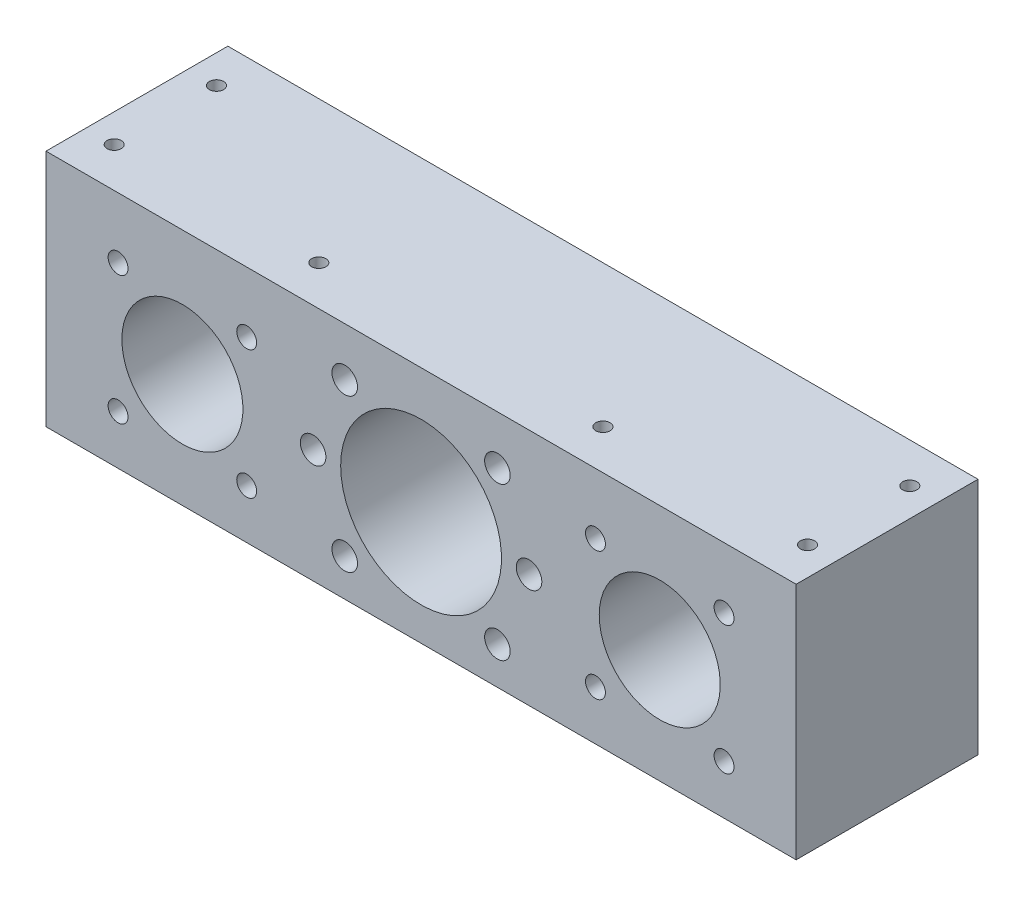
from build123d import *

# Parameters (mm, degrees)
SKETCH_1_W           = 132
SKETCH_1_H           = 42
EXTRUDE_1_DEPTH      = 32
SKETCH_2_R           = 14.15
CUT_EXTRUDE_1_DEPTH  = 32
SKETCH_3_R           = 10.65
CUT_EXTRUDE_2_DEPTH  = 32
SKETCH_7_R           = 2.25
SKETCH_7_R_2         = 1.75
CUT_EXTRUDE_8_DEPTH  = 32
CUT_EXTRUDE_9_DEPTH  = 10
CUT_EXTRUDE_10_DEPTH = 6
SKETCH_10_R          = 1.25
CUT_EXTRUDE_26_DEPTH = 10


with BuildPart() as part:
    # 草图1 → 凸台-拉伸1 (new body)
    with BuildSketch(Plane.XY):
        with Locations((0, 1)):
            Rectangle(SKETCH_1_W, SKETCH_1_H)
    extrude(amount=EXTRUDE_1_DEPTH)

    # 草图2 → 切除-拉伸1 (cut)
    with BuildSketch(Plane(origin=(0, 0, 0), x_dir=(-1, 0, 0), z_dir=(0, 0, -1))):
        Circle(SKETCH_2_R)
    extrude(amount=-CUT_EXTRUDE_1_DEPTH, mode=Mode.SUBTRACT)

    # 草图3 → 切除-拉伸2 (cut)
    with BuildSketch(Plane(origin=(0, 0, 0), x_dir=(-1, 0, 0), z_dir=(0, 0, -1))):
        with Locations((-42, 0)):
            Circle(SKETCH_3_R)
        with Locations((42, 0)):
            Circle(SKETCH_3_R)
    extrude(amount=-CUT_EXTRUDE_2_DEPTH, mode=Mode.SUBTRACT)

    # 草图7 → 切除-拉伸8 (cut)
    with BuildSketch(Plane(origin=(0, 0, 0), x_dir=(-1, 0, 0), z_dir=(0, 0, -1))):
        with Locations((-13.435028843, 13.435028843)):
            Circle(SKETCH_7_R)
        with Locations((13.435028843, 13.435028843)):
            Circle(SKETCH_7_R)
        with Locations((13.435028843, -13.435028843)):
            Circle(SKETCH_7_R)
        with Locations((-13.435028843, -13.435028843)):
            Circle(SKETCH_7_R)
        with Locations((-18.998610576, 0)):
            Circle(SKETCH_7_R)
        with Locations((18.998532389, 0)):
            Circle(SKETCH_7_R)
        with Locations((30.686291501, 11.313708499)):
            Circle(SKETCH_7_R_2)
        with Locations((30.686291501, -11.313708499)):
            Circle(SKETCH_7_R_2)
        with Locations((53.313708499, 11.313708499)):
            Circle(SKETCH_7_R_2)
        with Locations((53.313708499, -11.313708499)):
            Circle(SKETCH_7_R_2)
        with Locations((-53.313708499, 11.313708499)):
            Circle(SKETCH_7_R_2)
        with Locations((-30.686291501, 11.313708499)):
            Circle(SKETCH_7_R_2)
        with Locations((-53.313708499, -11.313708499)):
            Circle(SKETCH_7_R_2)
        with Locations((-30.686291501, -11.313708499)):
            Circle(SKETCH_7_R_2)
    extrude(amount=-CUT_EXTRUDE_8_DEPTH, mode=Mode.SUBTRACT)

    # 草图8 → 切除-拉伸9 (cut)
    with BuildSketch(Plane(origin=(0, 0, 0), x_dir=(-1, 0, 0), z_dir=(0, 0, -1))):
        with BuildLine():
            Line((-13.417246364, 20.2), (13.417246364, 20.2))
            ThreePointArc((13.417246364, 20.2), (24.249341133, 0.178758535), (13.713588152, -20))
            Line((13.713588152, -20), (-13.713588152, -20))
            ThreePointArc((-13.713588152, -20), (-24.249341133, 0.178758535), (-13.417246364, 20.2))
        make_face()
    extrude(amount=-CUT_EXTRUDE_9_DEPTH, mode=Mode.SUBTRACT)

    # 草图9 → 切除-拉伸10 (cut)
    with BuildSketch(Plane(origin=(0, 0, 0), x_dir=(-1, 0, 0), z_dir=(0, 0, -1))):
        with BuildLine():
            Line((28.306936062, 16.25), (55.693063938, 16.25))
            ThreePointArc((55.693063938, 16.25), (57.0260191, 15.0260191), (58.25, 13.693063938))
            Line((58.25, 13.693063938), (58.25, -13.693063938))
            ThreePointArc((58.25, -13.693063938), (57.0260191, -15.0260191), (55.693063938, -16.25))
            Line((55.693063938, -16.25), (28.306936062, -16.25))
            ThreePointArc((28.306936062, -16.25), (26.9739809, -15.0260191), (25.75, -13.693063938))
            Line((25.75, -13.693063938), (25.75, 13.693063938))
            ThreePointArc((25.75, 13.693063938), (26.9739809, 15.0260191), (28.306936062, 16.25))
        make_face()
        with BuildLine():
            Line((-55.693063938, 16.25), (-28.306936062, 16.25))
            ThreePointArc((-28.306936062, 16.25), (-26.9739809, 15.0260191), (-25.75, 13.693063938))
            Line((-25.75, 13.693063938), (-25.75, -13.693063938))
            ThreePointArc((-25.75, -13.693063938), (-26.9739809, -15.0260191), (-28.306936062, -16.25))
            Line((-28.306936062, -16.25), (-55.693063938, -16.25))
            ThreePointArc((-55.693063938, -16.25), (-57.0260191, -15.0260191), (-58.25, -13.693063938))
            Line((-58.25, -13.693063938), (-58.25, 13.693063938))
            ThreePointArc((-58.25, 13.693063938), (-57.0260191, 15.0260191), (-55.693063938, 16.25))
        make_face()
    extrude(amount=-CUT_EXTRUDE_10_DEPTH, mode=Mode.SUBTRACT)

    # 草图10 → 切除-拉伸26 (cut)
    with BuildSketch(Plane(origin=(0, 22, 0), x_dir=(1, 0, 0), z_dir=(0, 1, 0))):
        with Locations((25, -25)):
            Circle(SKETCH_10_R)
        with Locations((61, -25)):
            Circle(SKETCH_10_R)
        with Locations((-25, -25)):
            Circle(SKETCH_10_R)
        with Locations((-61, -25)):
            Circle(SKETCH_10_R)
        with Locations((61, -7)):
            Circle(SKETCH_10_R)
        with Locations((-61, -7)):
            Circle(SKETCH_10_R)
    extrude(amount=-CUT_EXTRUDE_26_DEPTH, mode=Mode.SUBTRACT)


solid = part.part
